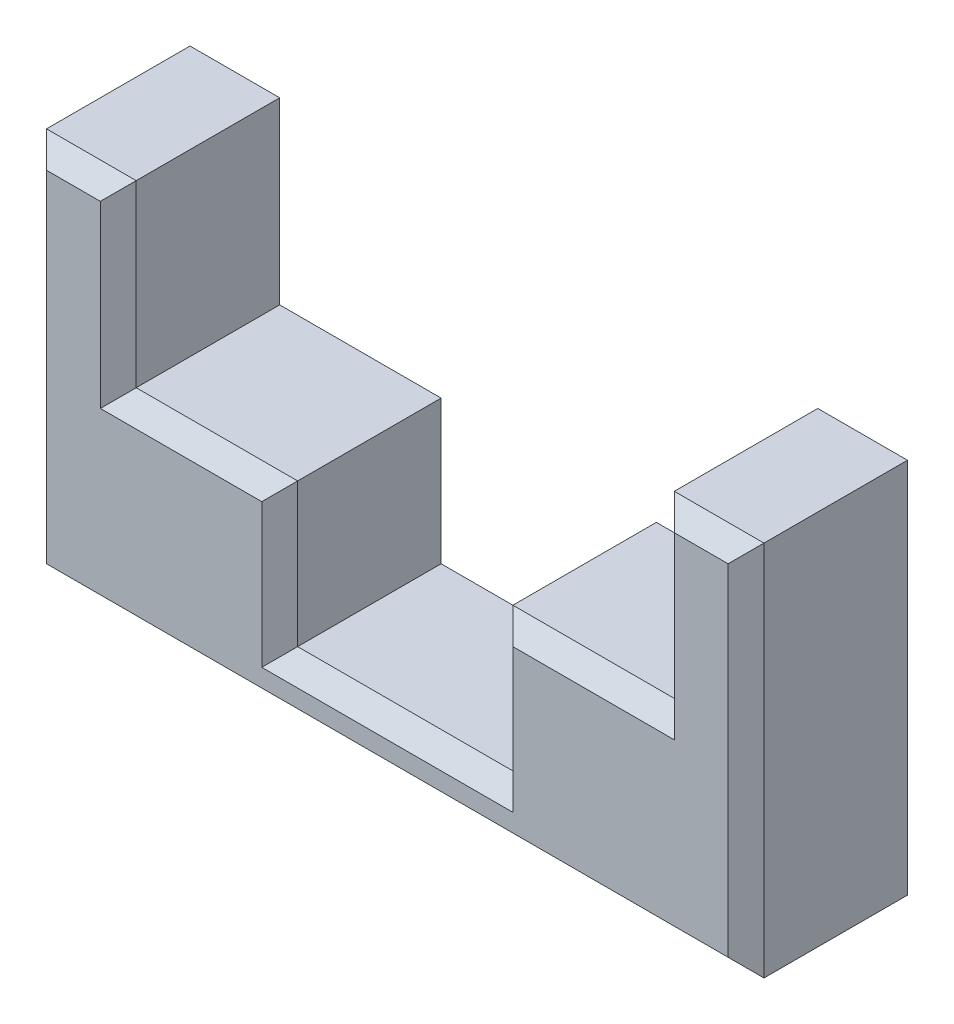
from build123d import *

# Parameters (mm, degrees)
BOSS_EXTRUDE1_DEPTH = 10
CHAMFER1_SIZE       = 1


with BuildPart() as part:
    # Sketch1 → Boss-Extrude1 (new body)
    with BuildSketch(Plane.XY):
        Polygon((-14.285879212, 0), (-14.285879212, -10), (-5.285879212, -10), (-5.285879212, -18), (6.714120788, -18), (6.714120788, -10), (15.714120788, -10), (15.714120788, 0), (20.714120788, 0), (20.714120788, -21), (-19.285879212, -21), (-19.285879212, 0), align=None)
    extrude(amount=BOSS_EXTRUDE1_DEPTH)

    # Chamfer1
    chamfer1_edges = [part.edges().sort_by_distance(p)[0] for p in [
        (20.714120788, -10.5, 0),
        (0.714120788, -21, 0),
        (11.214120788, -10, 10),
        (-19.285879212, -10.5, 0),
        (-16.785879212, 0, 0),
        (-14.285879212, -5, 0),
        (-9.785879212, -10, 0),
        (-5.285879212, -14, 0),
        (0.714120788, -18, 0),
        (6.714120788, -14, 0),
        (11.214120788, -10, 0),
        (15.714120788, -5, 0),
        (18.214120788, 0, 0),
        (6.714120788, -14, 10),
        (0.714120788, -18, 10),
        (-5.285879212, -14, 10),
        (-9.785879212, -10, 10),
        (-14.285879212, -5, 10),
        (-16.785879212, 0, 10),
        (-19.285879212, -10.5, 10),
        (0.714120788, -21, 10),
        (20.714120788, -10.5, 10),
        (18.214120788, 0, 10),
        (15.714120788, -5, 10),
    ]]
    chamfer(chamfer1_edges, length=CHAMFER1_SIZE)


solid = part.part
